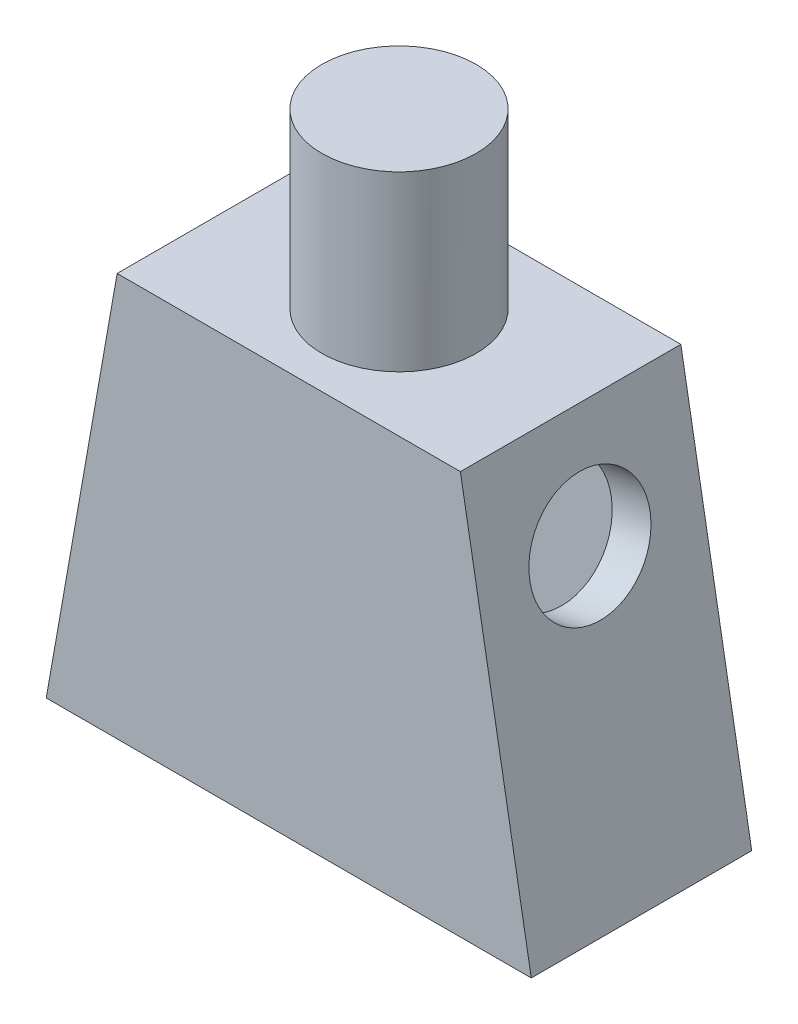
from build123d import *

# Parameters (mm, degrees)
EXTRUDE1_DEPTH = 7
SHELL1_T       = -1.25
SKETCH2_R      = 2.45
EXTRUDE2_DEPTH = 5.5
EXTRUDE3_REACH = 17.167
SKETCH3_R      = 1.91
EXTRUDE4_REACH = 17.167
SKETCH4_R      = 1.91


with BuildPart() as part:
    # Sketch1 → Extrude1 (new body)
    with BuildSketch(Plane.XY):
        Polygon((-5.45, 6.4), (-7.7, -6.4), (7.7, -6.4), (5.45, 6.4), align=None)
    extrude(amount=EXTRUDE1_DEPTH)

    # Shell1
    shell1_openings = [part.faces().sort_by_distance(p)[0] for p in [
        (0, -6.4, 3.5),
    ]]
    offset(amount=SHELL1_T, openings=shell1_openings, kind=Kind.INTERSECTION)

    # Sketch2 → Extrude2 (add)
    with BuildSketch(Plane(origin=(0, 6.4, 0), x_dir=(1, 0, 0), z_dir=(0, 1, 0))):
        with Locations((0, -3.5)):
            Circle(SKETCH2_R)
    extrude(amount=EXTRUDE2_DEPTH)

    # Sketch3 → Extrude3 (cut, up to next)
    with BuildSketch(Plane(origin=(-6.377928095, 1.121120173, 0), x_dir=(0, 0, 1), z_dir=(-0.984899531, 0.173126871, 0)), mode=Mode.PRIVATE) as extrude3_sk1:
        with Locations((3.5, 1.819815554)):
            Circle(SKETCH3_R)
    extrude3_tool1 = extrude(extrude3_sk1.sketch, amount=-EXTRUDE3_REACH, mode=Mode.PRIVATE) & part.part
    add(extrude3_tool1.solids().sort_by_distance((-6.062869, 2.913456, 3.5))[0], mode=Mode.SUBTRACT)

    # Sketch4 → Extrude4 (cut, up to next)
    with BuildSketch(Plane(origin=(6.377928095, 1.121120173, 0), x_dir=(0, 0, -1), z_dir=(0.984899531, 0.173126871, 0)), mode=Mode.PRIVATE) as extrude4_sk1:
        with Locations((-3.5, 1.819815554)):
            Circle(SKETCH4_R)
    extrude4_tool1 = extrude(extrude4_sk1.sketch, amount=-EXTRUDE4_REACH, mode=Mode.PRIVATE) & part.part
    add(extrude4_tool1.solids().sort_by_distance((6.062869, 2.913456, 3.5))[0], mode=Mode.SUBTRACT)


solid = part.part
